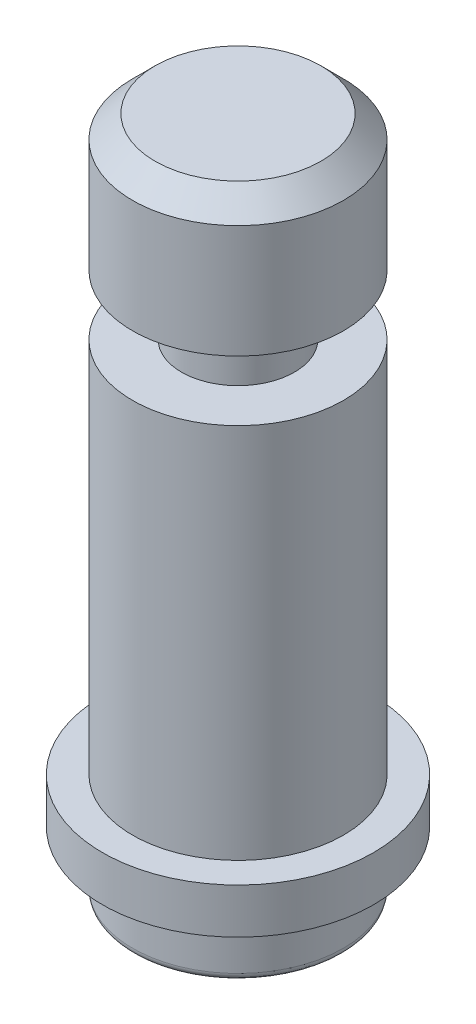
from build123d import *

# Parameters (mm, degrees)
CHAFL_N1_SIZE = 1.5
REDONDEO1_R   = 0.5


with BuildPart() as part:
    # Croquis1 → Revolución1 (revolve)
    with BuildSketch(Plane.XY):
        Polygon((0, -22.5), (7, -22.5), (7, -18.5), (9, -18.5), (9, -15.5), (7, -15.5), (7, 9.5), (3.75, 9.5), (3.75, 13.5), (7, 13.5), (7, 22.5), (0, 22.5), align=None)
    revolve(axis=Axis((0, 22.5, 0), (0, -1, 0)))

    # Chaflán1
    chafl_n1_edges = [part.edges().sort_by_distance(p)[0] for p in [
        (-7, 22.5, 0),
    ]]
    chamfer(chafl_n1_edges, length=CHAFL_N1_SIZE)

    # Redondeo1
    redondeo1_edges = [part.edges().sort_by_distance(p)[0] for p in [
        (-7, -22.5, 0),
    ]]
    fillet(redondeo1_edges, radius=REDONDEO1_R)


solid = part.part
